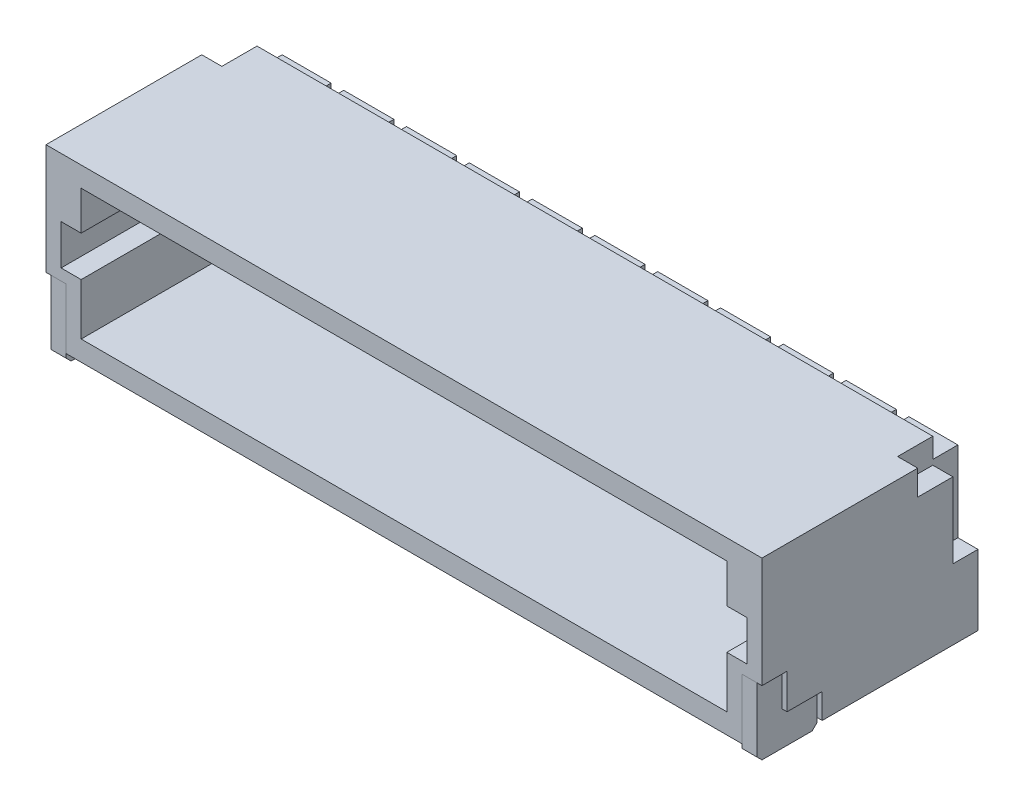
from build123d import *

# Parameters (mm, degrees)
SKETCH1_W               = 8
SKETCH1_H               = 3.4
BOSS_EXTRUDE1_DEPTH     = 2.15
CUT_EXTRUDE1_DEPTH      = 3
CUT_EXTRUDE2_DEPTH      = 0.4
CUT_EXTRUDE3_DEPTH      = 0.5
SKETCH7_W               = 0.25
SKETCH7_H               = 0.3
CUT_EXTRUDE4_DEPTH      = 1.4
CUT_EXTRUDE4_DEPTH_BACK = 4
SKETCH8_W               = 0.25
SKETCH8_H               = 0.25
CUT_EXTRUDE5_DEPTH      = 4
CUT_EXTRUDE5_DEPTH_BACK = 2.3
BOSS_EXTRUDE2_DEPTH     = 0.125
CHAMFER2_SIZE           = 0.1
LPATTERN1_COUNT         = 3
LPATTERN1_PITCH         = 1.25
LPATTERN1_2_COUNT       = 3
LPATTERN1_2_PITCH       = 1.25
BOSS_EXTRUDE3_DEPTH     = 0.3
CHAMFER1_SIZE           = 0.1
SKETCH11_W              = 0.875
SKETCH11_H              = 3.58
CUT_EXTRUDE6_DEPTH      = 1
CUT_EXTRUDE6_DEPTH_BACK = 6.1


with BuildPart() as part:
    # Sketch1 → Boss-Extrude1 (new body, symmetric)
    with BuildSketch(Plane.XY):
        Rectangle(SKETCH1_W, SKETCH1_H)
    extrude(amount=BOSS_EXTRUDE1_DEPTH, both=True)

    # Sketch2 → Cut-Extrude1 (cut)
    with BuildSketch(Plane.XY.offset(2.15)):
        Polygon((3.3, -1.3), (-3.3, -1.3), (-3.3, -0.275), (-3.7, -0.275), (-3.7, 0.525), (-3.3, 0.525), (-3.3, 1.3), (3.3, 1.3), (3.3, 0.525), (3.7, 0.525), (3.7, -0.275), (3.3, -0.275), align=None)
    extrude(amount=-CUT_EXTRUDE1_DEPTH, mode=Mode.SUBTRACT)

    # Sketch5 → Cut-Extrude2 (cut)
    with BuildSketch(Plane.ZY.offset(4)):
        Polygon((2.15, -1.7), (2.15, -0.5), (1.65, -0.5), (1.65, -1.2), (0.95, -1.2), (0.95, -1.7), align=None)
        Polygon((-1.65, 1.2), (-0.95, 1.2), (-0.95, 1.7), (-2.15, 1.7), (-2.15, 0.5), (-1.65, 0.5), align=None)
    cut_extrude2 = extrude(amount=-CUT_EXTRUDE2_DEPTH, mode=Mode.SUBTRACT)

    # Mirror1: Cut-Extrude2 across plane
    add(cut_extrude2.mirror(Plane(origin=(0, 0, 0), x_dir=(0, 0, 1), z_dir=(1, 0, 0))), mode=Mode.SUBTRACT)

    # Sketch6 → Cut-Extrude3 (cut)
    with BuildSketch(Plane(origin=(0, 0, -2.15), x_dir=(-1, 0, 0), z_dir=(0, 0, -1))):
        Polygon((-4, 1.7), (-4, -0.3), (-3.6, -0.3), (-3.6, 1.3), (3.6, 1.3), (3.6, -0.3), (4, -0.3), (4, 1.7), align=None)
    extrude(amount=-CUT_EXTRUDE3_DEPTH, mode=Mode.SUBTRACT)

    # Sketch7 → Cut-Extrude4 (cut, two sides)
    with BuildSketch(Plane(origin=(0, 1.3, 0), x_dir=(1, 0, 0), z_dir=(0, 1, 0))) as cut_extrude4_sk:
        with Locations((1.25, 2)):
            Rectangle(SKETCH7_W, SKETCH7_H)
        with Locations((-1.25, 2)):
            Rectangle(SKETCH7_W, SKETCH7_H)
        with Locations((-2.5, 2)):
            Rectangle(SKETCH7_W, SKETCH7_H)
        with Locations((0, 2)):
            Rectangle(SKETCH7_W, SKETCH7_H)
        with Locations((2.5, 2)):
            Rectangle(SKETCH7_W, SKETCH7_H)
    extrude(amount=CUT_EXTRUDE4_DEPTH, mode=Mode.SUBTRACT)
    extrude(cut_extrude4_sk.sketch, amount=-CUT_EXTRUDE4_DEPTH_BACK, mode=Mode.SUBTRACT)

    # Sketch8 → Cut-Extrude5 (cut, two sides)
    with BuildSketch(Plane.XY.offset(-0.85)) as cut_extrude5_sk:
        with Locations((-2.5, 0.875)):
            Rectangle(SKETCH8_W, SKETCH8_H)
        with Locations((-1.25, 0.875)):
            Rectangle(SKETCH8_W, SKETCH8_H)
        with Locations((1.25, 0.875)):
            Rectangle(SKETCH8_W, SKETCH8_H)
        with Locations((0, 0.875)):
            Rectangle(SKETCH8_W, SKETCH8_H)
        with Locations((2.5, 0.875)):
            Rectangle(SKETCH8_W, SKETCH8_H)
    extrude(amount=CUT_EXTRUDE5_DEPTH, mode=Mode.SUBTRACT)
    extrude(cut_extrude5_sk.sketch, amount=-CUT_EXTRUDE5_DEPTH_BACK, mode=Mode.SUBTRACT)


with BuildPart() as body_2:
    # Sketch9 → Boss-Extrude2 (new body, symmetric)
    with BuildSketch(Plane(origin=(0, 0, 0), x_dir=(0, 0, -1), z_dir=(1, 0, 0))):
        Polygon((1.85, -1.88), (2.95, -1.88), (2.95, -1.63), (2.15, -1.63), (2.15, 1), (-0.45, 1), (-0.45, 0.75), (1.85, 0.75), align=None)
    extrude(amount=BOSS_EXTRUDE2_DEPTH, both=True)

    # Chamfer2
    chamfer2_edges = [body_2.edges().sort_by_distance(p)[0] for p in [
        (0, -1.88, -1.85),
    ]]
    chamfer(chamfer2_edges, length=CHAMFER2_SIZE)


with BuildPart() as lpattern1_1:
    # LPattern1: pattern copy
    add(body_2.part.moved(Location(Vector(1, 0, 0) * (1 * LPATTERN1_PITCH))))


with BuildPart() as lpattern1_2:
    # LPattern1: pattern copy
    add(body_2.part.moved(Location(Vector(1, 0, 0) * (2 * LPATTERN1_PITCH))))


with BuildPart() as lpattern1_2_1:
    # LPattern1 2: pattern copy
    add(body_2.part.moved(Location(Vector(-1, 0, 0) * (1 * LPATTERN1_2_PITCH))))


with BuildPart() as lpattern1_2_2:
    # LPattern1 2: pattern copy
    add(body_2.part.moved(Location(Vector(-1, 0, 0) * (2 * LPATTERN1_2_PITCH))))


with BuildPart() as body_7:
    # Sketch10 → Boss-Extrude3 (new body)
    with BuildSketch(Plane(origin=(3.6, 0, 0), x_dir=(0, 0, -1), z_dir=(1, 0, 0))):
        Polygon((-2.15, -0.5), (-2.15, -1.88), (-0.95, -1.88), (-0.95, -1.2), (-1.65, -1.2), (-1.65, -0.5), align=None)
    extrude(amount=BOSS_EXTRUDE3_DEPTH)

    # Chamfer1
    chamfer1_edges = [body_7.edges().sort_by_distance(p)[0] for p in [
        (3.75, -1.88, 0.95),
        (3.75, -1.88, 2.15),
    ]]
    chamfer(chamfer1_edges, length=CHAMFER1_SIZE)


with BuildPart() as body_8:
    # Mirror2: mirrored copy
    add(body_7.part.mirror(Plane(origin=(0, 0, 0), x_dir=(0, 0, 1), z_dir=(1, 0, 0))))


with BuildPart() as cut_extrude6_tool:
    # Sketch11 → Cut-Extrude6 (new body, two sides)
    with BuildSketch(Plane.XY.offset(2.15)) as cut_extrude6_sk:
        with Locations((3.5625, -0.09)):
            Rectangle(SKETCH11_W, SKETCH11_H)
    extrude(amount=CUT_EXTRUDE6_DEPTH)
    extrude(cut_extrude6_sk.sketch, amount=-CUT_EXTRUDE6_DEPTH_BACK)


with BuildPart() as part_1:
    add(part.part)

    # Cut-Extrude6: cut by cut_extrude6_tool
    add(cut_extrude6_tool.part, mode=Mode.SUBTRACT)


with BuildPart() as body_7_1:
    add(body_7.part)

    # Cut-Extrude6: cut by cut_extrude6_tool
    add(cut_extrude6_tool.part, mode=Mode.SUBTRACT)


with BuildPart() as body_8_2:
    # Mirror3: mirrored copy
    add(body_2.part.mirror(Plane(origin=(3.125, 1.7, -2.95), x_dir=(0, 0, 1), z_dir=(-1, 0, 0))))


with BuildPart() as body_9:
    # Mirror3 2: mirrored copy
    add(part_1.part.mirror(Plane(origin=(3.125, 1.7, -2.95), x_dir=(0, 0, 1), z_dir=(-1, 0, 0))))

    # Combine1: union part
    add(part_1.part)


with BuildPart() as body_10:
    # Mirror3 3: mirrored copy
    add(body_8.part.mirror(Plane(origin=(3.125, 1.7, -2.95), x_dir=(0, 0, 1), z_dir=(-1, 0, 0))))


with BuildPart() as body_11:
    # Mirror3 4: mirrored copy
    add(lpattern1_2_2.part.mirror(Plane(origin=(3.125, 1.7, -2.95), x_dir=(0, 0, 1), z_dir=(-1, 0, 0))))


with BuildPart() as body_12:
    # Mirror3 5: mirrored copy
    add(lpattern1_2_1.part.mirror(Plane(origin=(3.125, 1.7, -2.95), x_dir=(0, 0, 1), z_dir=(-1, 0, 0))))


with BuildPart() as body_13:
    # Mirror3 6: mirrored copy
    add(lpattern1_2.part.mirror(Plane(origin=(3.125, 1.7, -2.95), x_dir=(0, 0, 1), z_dir=(-1, 0, 0))))


with BuildPart() as body_14:
    # Mirror3 7: mirrored copy
    add(lpattern1_1.part.mirror(Plane(origin=(3.125, 1.7, -2.95), x_dir=(0, 0, 1), z_dir=(-1, 0, 0))))


solid = Compound([body_2.part, lpattern1_1.part, lpattern1_2.part, lpattern1_2_1.part, lpattern1_2_2.part, body_8.part, body_8_2.part, body_9.part, body_10.part, body_11.part, body_12.part, body_13.part, body_14.part])
